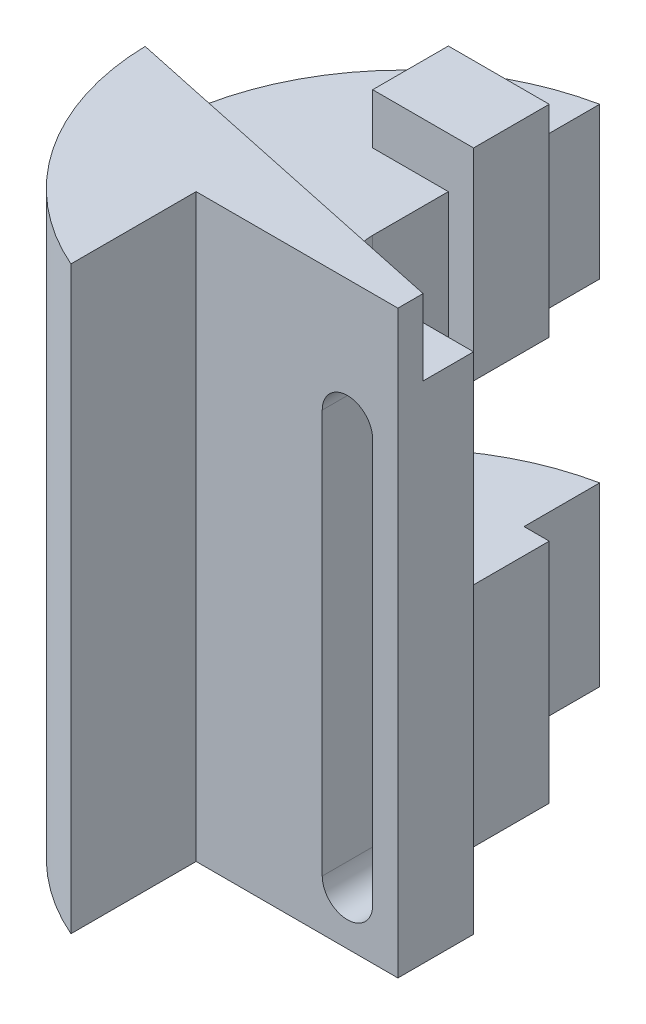
from build123d import *

# Parameters (mm, degrees)
BOSS_EXTRUDE1_DEPTH = 115
SKETCH2_W           = 40
SKETCH2_H           = 35
CUT_EXTRUDE1_DEPTH  = 41
CUT_EXTRUDE2_REACH  = 41.816
SKETCH4_W           = 15
SKETCH4_H           = 45
SKETCH4_H_2         = 40
BOSS_EXTRUDE2_DEPTH = 5
CUT_EXTRUDE3_DEPTH  = 15
SKETCH7_W           = 15
SKETCH7_H           = 15
BOSS_EXTRUDE3_DEPTH = 10
SKETCH8_W           = 15.002545061
SKETCH8_H           = 15
BOSS_EXTRUDE4_DEPTH = 10


with BuildPart() as part:
    # Sketch1 → Boss-Extrude1 (new body)
    with BuildSketch(Plane(origin=(0, 0, 0), x_dir=(1, 0, 0), z_dir=(0, 1, 0))):
        with BuildLine():
            Line((0, 0), (0, -15))
            Line((0, -15), (-40, -15))
            Line((-40, -15), (-40, -39.815551805))
            ThreePointArc((-40, -39.815551805), (-69.724211568, 11.254514819), (-30, 55))
            Line((-30, 55), (-30, 10))
            ThreePointArc((-30, 10), (-27.071067812, 2.928932188), (-20, 0))
            Line((-20, 0), (0, 0))
        make_face()
    extrude(amount=BOSS_EXTRUDE1_DEPTH)

    # Sketch2 → Cut-Extrude1 (cut, through all)
    with BuildSketch(Plane(origin=(-30, 0, 0), x_dir=(0, 0, -1), z_dir=(1, 0, 0))):
        with Locations((35, 52.5)):
            Rectangle(SKETCH2_W, SKETCH2_H)
    extrude(amount=-CUT_EXTRUDE1_DEPTH, mode=Mode.SUBTRACT)

    # Sketch3 → Cut-Extrude2 (cut, up to next)
    with BuildSketch(Plane(origin=(0, 0, 0), x_dir=(-1, 0, 0), z_dir=(0, 0, -1)), mode=Mode.PRIVATE) as cut_extrude2_sk1:
        with BuildLine():
            Line((15, 90), (15, 10))
            ThreePointArc((15, 10), (10, 5), (5, 10))
            Line((5, 10), (5, 90))
            ThreePointArc((5, 90), (10, 95), (15, 90))
        make_face()
    cut_extrude2_tool1 = extrude(cut_extrude2_sk1.sketch, amount=-CUT_EXTRUDE2_REACH, mode=Mode.PRIVATE) & part.part
    add(cut_extrude2_tool1.solids().sort_by_distance((-10, 50, 0))[0], mode=Mode.SUBTRACT)

    # Sketch4 → Boss-Extrude2 (add)
    with BuildSketch(Plane(origin=(-30, 0, 0), x_dir=(0, 0, -1), z_dir=(1, 0, 0))):
        with Locations((32.5, 12.5)):
            Rectangle(SKETCH4_W, SKETCH4_H)
        with Locations((32.5, 90)):
            Rectangle(SKETCH4_W, SKETCH4_H_2)
    extrude(amount=BOSS_EXTRUDE2_DEPTH)

    # Sketch6 → Cut-Extrude3 (cut)
    with BuildSketch(Plane(origin=(0, 115, 0), x_dir=(1, 0, 0), z_dir=(0, 1, 0))):
        with BuildLine():
            Line((0, -10), (-69.987139252, 4.87622568))
            ThreePointArc((-69.987139252, 4.87622568), (-59.085961763, 37.191731616), (-30, 55))
            Line((-30, 55), (-30, 10))
            ThreePointArc((-30, 10), (-27.071067812, 2.928932188), (-20, 0))
            Line((-20, 0), (0, 0))
            Line((0, 0), (0, -10))
        make_face()
    extrude(amount=-CUT_EXTRUDE3_DEPTH, mode=Mode.SUBTRACT)

    # Sketch7 → Boss-Extrude3 (add)
    with BuildSketch(Plane(origin=(0, 100, 0), x_dir=(1, 0, 0), z_dir=(0, 1, 0))):
        with Locations((-37.5, 32.5)):
            Rectangle(SKETCH7_W, SKETCH7_H)
    extrude(amount=BOSS_EXTRUDE3_DEPTH)

    # Sketch8 → Boss-Extrude4 (add)
    with BuildSketch(Plane.XZ):
        with Locations((-37.501272531, -32.5)):
            Rectangle(SKETCH8_W, SKETCH8_H)
    extrude(amount=BOSS_EXTRUDE4_DEPTH)


solid = part.part
